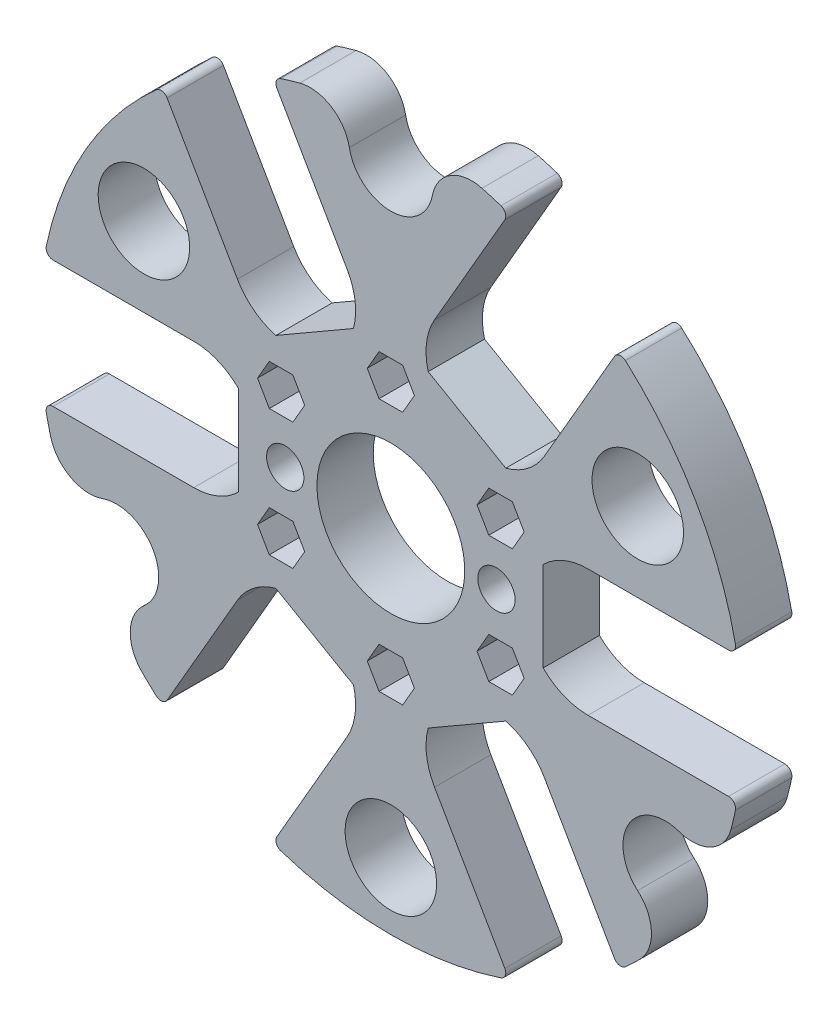
from build123d import *

# Parameters (mm, degrees)
SKETCH_1_W                  = 50
SKETCH_1_H                  = 8
CUT_EXTRUDE_1_DEPTH         = 9
CUT_EXTRUDE_2_DEPTH         = 9
CUT_EXTRUDE_3_DEPTH         = 9
CUT_EXTRUDE_4_DEPTH         = 9
CUT_EXTRUDE_5_DEPTH         = 9
CUT_EXTRUDE_6_DEPTH         = 9
CUT_EXTRUDE_7_DEPTH         = 5
CUT_EXTRUDE_8_DEPTH         = 5
CUT_EXTRUDE_9_DEPTH         = 5
CUT_EXTRUDE_10_DEPTH        = 5
CUT_EXTRUDE_11_DEPTH        = 5
CUT_EXTRUDE_12_DEPTH        = 5
HOLE_WIZARD_3_6_3_6_1_D     = 3.6
HOLE_WIZARD_3_6_3_6_1_DEPTH = 8
HOLE_WIZARD_5_3_5_3_1_D     = 5.3
HOLE_WIZARD_5_3_5_3_1_DEPTH = 8
HOLE_WIZARD_21_0_21_1_D     = 21
HOLE_WIZARD_21_0_21_1_DEPTH = 8
HOLE_WIZARD_13_0_13_1_D     = 13
HOLE_WIZARD_13_0_13_1_DEPTH = 8
HOLE_WIZARD_12_0_12_1_D     = 12
HOLE_WIZARD_12_0_12_1_DEPTH = 8
FILLET_1_R                  = 1
FILLET_2_R                  = 5.678207345


with BuildPart() as part:
    # 草图1 → 旋转1 (revolve)
    with BuildSketch(Plane.XZ):
        with Locations((475, 4)):
            Rectangle(SKETCH_1_W, SKETCH_1_H)
    revolve(axis=Axis((450, 0, 8), (0, 0, -1)))

    # 草图2 → 切除-拉伸1 (cut, through all)
    with BuildSketch(Plane(origin=(0, 0, 0), x_dir=(-1, 0, 0), z_dir=(0, 0, -1))):
        with BuildLine():
            Line((-499.183330509, -9), (-478, -9))
            ThreePointArc((-478, -9), (-474.555849109, -8.314915793), (-471.636038969, -6.363961031))
            Line((-471.636038969, -6.363961031), (-471.636038969, 6.363961031))
            ThreePointArc((-471.636038969, 6.363961031), (-474.555849109, 8.314915793), (-478, 9))
            Line((-478, 9), (-499.183330509, 9))
            ThreePointArc((-499.183330509, 9), (-500, 0), (-499.183330509, -9))
        make_face()
    extrude(amount=-CUT_EXTRUDE_1_DEPTH, mode=Mode.SUBTRACT)

    # 草图3 → 切除-拉伸2 (cut, through all)
    with BuildSketch(Plane(origin=(0, 0, 0), x_dir=(-1, 0, 0), z_dir=(0, 0, -1))):
        with BuildLine():
            Line((-482.385893889, 38.094013664), (-471.794228634, 19.748711306))
            ThreePointArc((-471.794228634, 19.748711306), (-469.478852861, 17.108531243), (-466.329371406, 15.555378869))
            Line((-466.329371406, 15.555378869), (-455.306667563, 21.9193399))
            ThreePointArc((-455.306667563, 21.9193399), (-455.076996248, 25.423447036), (-456.205771366, 28.748711306))
            Line((-456.205771366, 28.748711306), (-466.797436621, 47.094013664))
            ThreePointArc((-466.797436621, 47.094013664), (-475, 43.301270189), (-482.385893889, 38.094013664))
        make_face()
    extrude(amount=-CUT_EXTRUDE_2_DEPTH, mode=Mode.SUBTRACT)

    # 草图4 → 切除-拉伸3 (cut, through all)
    with BuildSketch(Plane(origin=(0, 0, 0), x_dir=(-1, 0, 0), z_dir=(0, 0, -1))):
        with BuildLine():
            Line((-433.202563379, 47.094013664), (-443.794228634, 28.748711306))
            ThreePointArc((-443.794228634, 28.748711306), (-444.923003752, 25.423447036), (-444.693332437, 21.9193399))
            Line((-444.693332437, 21.9193399), (-433.670628594, 15.555378869))
            ThreePointArc((-433.670628594, 15.555378869), (-430.521147139, 17.108531243), (-428.205771366, 19.748711306))
            Line((-428.205771366, 19.748711306), (-417.614106111, 38.094013664))
            ThreePointArc((-417.614106111, 38.094013664), (-425, 43.301270189), (-433.202563379, 47.094013664))
        make_face()
    extrude(amount=-CUT_EXTRUDE_3_DEPTH, mode=Mode.SUBTRACT)

    # 草图5 → 切除-拉伸4 (cut, through all)
    with BuildSketch(Plane(origin=(0, 0, 0), x_dir=(-1, 0, 0), z_dir=(0, 0, -1))):
        with BuildLine():
            Line((-400.816669491, 9), (-422, 9))
            ThreePointArc((-422, 9), (-425.444150891, 8.314915793), (-428.363961031, 6.363961031))
            Line((-428.363961031, 6.363961031), (-428.363961031, -6.363961031))
            ThreePointArc((-428.363961031, -6.363961031), (-425.444150891, -8.314915793), (-422, -9))
            Line((-422, -9), (-400.816669491, -9))
            ThreePointArc((-400.816669491, -9), (-400, 0), (-400.816669491, 9))
        make_face()
    extrude(amount=-CUT_EXTRUDE_4_DEPTH, mode=Mode.SUBTRACT)

    # 草图6 → 切除-拉伸5 (cut, through all)
    with BuildSketch(Plane(origin=(0, 0, 0), x_dir=(-1, 0, 0), z_dir=(0, 0, -1))):
        with BuildLine():
            Line((-417.614106111, -38.094013664), (-428.205771366, -19.748711306))
            ThreePointArc((-428.205771366, -19.748711306), (-430.521147139, -17.108531243), (-433.670628594, -15.555378869))
            Line((-433.670628594, -15.555378869), (-444.693332437, -21.9193399))
            ThreePointArc((-444.693332437, -21.9193399), (-444.923003752, -25.423447036), (-443.794228634, -28.748711306))
            Line((-443.794228634, -28.748711306), (-433.202563379, -47.094013664))
            ThreePointArc((-433.202563379, -47.094013664), (-425, -43.301270189), (-417.614106111, -38.094013664))
        make_face()
    extrude(amount=-CUT_EXTRUDE_5_DEPTH, mode=Mode.SUBTRACT)

    # 草图7 → 切除-拉伸6 (cut, through all)
    with BuildSketch(Plane(origin=(0, 0, 0), x_dir=(-1, 0, 0), z_dir=(0, 0, -1))):
        with BuildLine():
            Line((-466.797436621, -47.094013664), (-456.205771366, -28.748711306))
            ThreePointArc((-456.205771366, -28.748711306), (-455.076996248, -25.423447036), (-455.306667563, -21.9193399))
            Line((-455.306667563, -21.9193399), (-466.329371406, -15.555378869))
            ThreePointArc((-466.329371406, -15.555378869), (-469.478852861, -17.108531243), (-471.794228634, -19.748711306))
            Line((-471.794228634, -19.748711306), (-482.385893889, -38.094013664))
            ThreePointArc((-482.385893889, -38.094013664), (-475, -43.301270189), (-466.797436621, -47.094013664))
        make_face()
    extrude(amount=-CUT_EXTRUDE_6_DEPTH, mode=Mode.SUBTRACT)

    # 草图8 → 切除-拉伸7 (cut)
    with BuildSketch(Plane.XY.offset(8)):
        Polygon((451.675, 15.098814897), (453.35, 18), (451.675, 20.901185103), (448.325, 20.901185103), (446.65, 18), (448.325, 15.098814897), align=None)
    extrude(amount=-CUT_EXTRUDE_7_DEPTH, mode=Mode.SUBTRACT)

    # 草图9 → 切除-拉伸8 (cut)
    with BuildSketch(Plane.XY.offset(8)):
        Polygon((436.086542732, 11.901185103), (432.736542732, 11.901185103), (431.061542732, 9), (432.736542732, 6.098814897), (436.086542732, 6.098814897), (437.761542732, 9), align=None)
    extrude(amount=-CUT_EXTRUDE_8_DEPTH, mode=Mode.SUBTRACT)

    # 草图10 → 切除-拉伸9 (cut)
    with BuildSketch(Plane.XY.offset(8)):
        Polygon((432.736542732, -6.098814897), (431.061542732, -9), (432.736542732, -11.901185103), (436.086542732, -11.901185103), (437.761542732, -9), (436.086542732, -6.098814897), align=None)
    extrude(amount=-CUT_EXTRUDE_9_DEPTH, mode=Mode.SUBTRACT)

    # 草图11 → 切除-拉伸10 (cut)
    with BuildSketch(Plane.XY.offset(8)):
        Polygon((446.65, -18), (448.325, -20.901185103), (451.675, -20.901185103), (453.35, -18), (451.675, -15.098814897), (448.325, -15.098814897), align=None)
    extrude(amount=-CUT_EXTRUDE_10_DEPTH, mode=Mode.SUBTRACT)

    # 草图12 → 切除-拉伸11 (cut)
    with BuildSketch(Plane.XY.offset(8)):
        Polygon((463.913457268, -11.901185103), (467.263457268, -11.901185103), (468.938457268, -9), (467.263457268, -6.098814897), (463.913457268, -6.098814897), (462.238457268, -9), align=None)
    extrude(amount=-CUT_EXTRUDE_11_DEPTH, mode=Mode.SUBTRACT)

    # 草图13 → 切除-拉伸12 (cut)
    with BuildSketch(Plane.XY.offset(8)):
        Polygon((467.263457268, 6.098814897), (468.938457268, 9), (467.263457268, 11.901185103), (463.913457268, 11.901185103), (462.238457268, 9), (463.913457268, 6.098814897), align=None)
    extrude(amount=-CUT_EXTRUDE_12_DEPTH, mode=Mode.SUBTRACT)

    # Ø3.6 (3.6) 直径孔1
    with Locations(Plane(origin=(0, 0, 0), x_dir=(-1, 0, 0), z_dir=(0, 0, -1))):
        with Locations((-450, 18), (-434.411542732, 9), (-434.411542732, -9), (-450, -18), (-465.588457268, -9), (-465.588457268, 9)):
            Hole(HOLE_WIZARD_3_6_3_6_1_D / 2, depth=HOLE_WIZARD_3_6_3_6_1_DEPTH)

    # Ø5.3 (5.3) 直径孔1
    with Locations(Plane(origin=(0, 0, 0), x_dir=(-1, 0, 0), z_dir=(0, 0, -1))):
        with Locations((-465, 0), (-435, 0)):
            Hole(HOLE_WIZARD_5_3_5_3_1_D / 2, depth=HOLE_WIZARD_5_3_5_3_1_DEPTH)

    # Ø21.0 (21) 直径孔1
    with Locations(Plane(origin=(0, 0, 0), x_dir=(-1, 0, 0), z_dir=(0, 0, -1))):
        with Locations((-450, 0)):
            Hole(HOLE_WIZARD_21_0_21_1_D / 2, depth=HOLE_WIZARD_21_0_21_1_DEPTH)

    # Ø13.0 (13) 直径孔1
    with Locations(Plane(origin=(0, 0, 0), x_dir=(-1, 0, 0), z_dir=(0, 0, -1))):
        with Locations((-450, -40.5), (-485.074028853, 20.25), (-414.925971147, 20.25)):
            Hole(HOLE_WIZARD_13_0_13_1_D / 2, depth=HOLE_WIZARD_13_0_13_1_DEPTH)

    # Ø12.0 (12) 直径孔1
    with Locations(Plane.XY.offset(8)):
        with Locations((488.97114317, -22.5), (450, 45), (411.02885683, -22.5)):
            Hole(HOLE_WIZARD_12_0_12_1_D / 2, depth=HOLE_WIZARD_12_0_12_1_DEPTH)

    # 圆角1
    fillet_1_edges = [part.edges().sort_by_distance(p)[0] for p in [
        (417.614106111, -38.094013664, 4),
        (433.202563379, -47.094013664, 4),
        (466.797436621, -47.094013664, 4),
        (482.385893889, -38.094013664, 4),
        (499.183330509, -9, 4),
        (499.183330509, 9, 4),
        (482.385893889, 38.094013664, 4),
        (466.797436621, 47.094013664, 4),
        (433.202563379, 47.094013664, 4),
        (417.614106111, 38.094013664, 4),
        (400.816669491, 9, 4),
        (400.816669491, -9, 4),
    ]]
    fillet(fillet_1_edges, radius=FILLET_1_R)

    # 圆角2
    fillet_2_edges = [part.edges().sort_by_distance(p)[0] for p in [
        (405.057631171, -21.913089332, 4),
        (408.551523549, -27.964688446, 4),
        (453.493892378, 49.877777778, 4),
        (446.506107622, 49.877777778, 4),
        (491.448476451, -27.964688446, 4),
        (494.942368829, -21.913089332, 4),
    ]]
    fillet(fillet_2_edges, radius=FILLET_2_R)


solid = part.part
